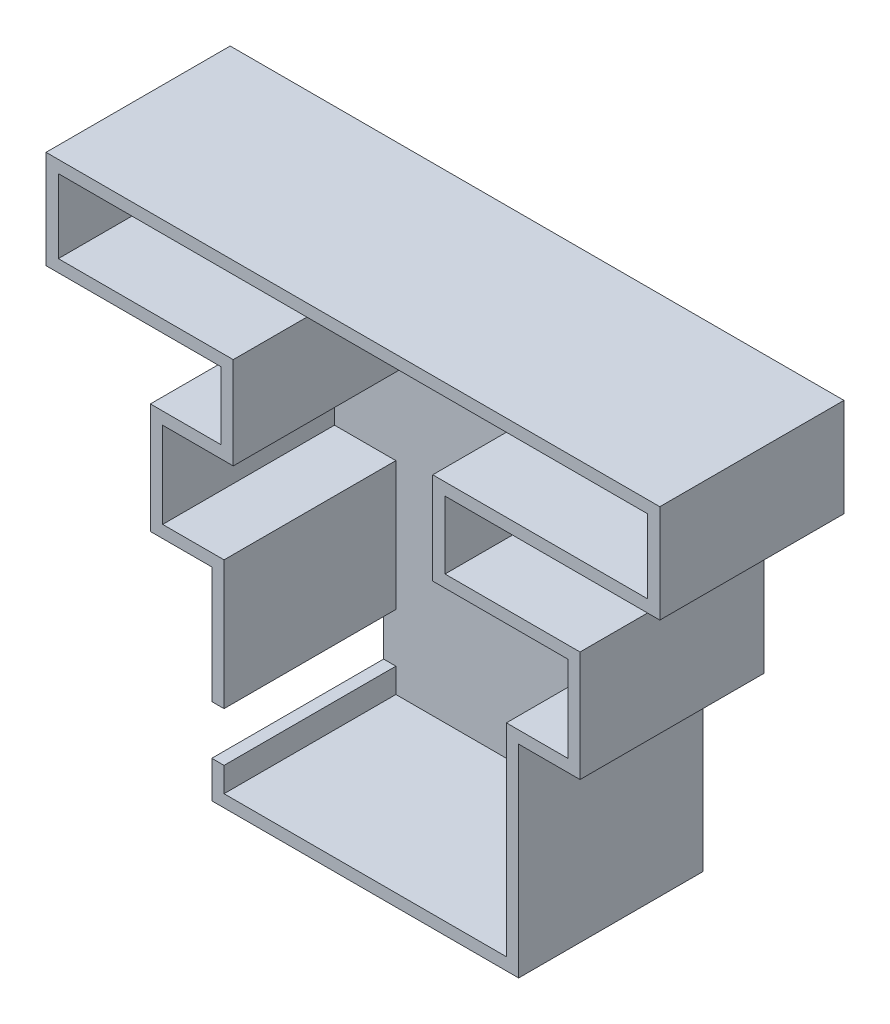
from build123d import *

# Parameters (mm, degrees)
EXTRUDE_1_DEPTH     = 15
CUT_EXTRUDE_1_DEPTH = 14
SKETCH_7_W          = 48
SKETCH_7_H          = 6
CUT_EXTRUDE_2_DEPTH = 1
SKETCH_8_W          = 14
SKETCH_8_H          = 4
CUT_EXTRUDE_3_DEPTH = 1


with BuildPart() as part:
    # 草图3 → 凸台-拉伸1 (new body)
    with BuildSketch(Plane.XY):
        Polygon((-26, 21.5), (24, 21.5), (24, 13.5), (6.5, 13.5), (6.5, 8), (17.5, 8), (17.5, -1), (12.5, -1), (12.5, -17.5), (-12.5, -17.5), (-12.5, -1), (-17.5, -1), (-17.5, 8), (-11.75, 8), (-11.75, 13.5), (-26, 13.5), align=None)
    extrude(amount=EXTRUDE_1_DEPTH)

    # 草图4 → 切除-拉伸1 (cut)
    with BuildSketch(Plane.XY.offset(15)):
        Polygon((23, 20.5), (-25, 20.5), (-25, 14.5), (-10.75, 14.5), (-10.75, 7), (-16.5, 7), (-16.5, 0), (-11.5, 0), (-11.5, -16.5), (11.5, -16.5), (11.5, 0), (16.5, 0), (16.5, 7), (5.5, 7), (5.5, 14.5), (23, 14.5), align=None)
    extrude(amount=-CUT_EXTRUDE_1_DEPTH, mode=Mode.SUBTRACT)

    # 草图7 → 切除-拉伸2 (cut)
    with BuildSketch(Plane.XY.offset(1)):
        with Locations((-1, 17.5)):
            Rectangle(SKETCH_7_W, SKETCH_7_H)
    extrude(amount=-CUT_EXTRUDE_2_DEPTH, mode=Mode.SUBTRACT)

    # 草图8 → 切除-拉伸3 (cut)
    with BuildSketch(Plane.ZY.offset(12.5)):
        with Locations((8, -12.5)):
            Rectangle(SKETCH_8_W, SKETCH_8_H)
    extrude(amount=-CUT_EXTRUDE_3_DEPTH, mode=Mode.SUBTRACT)


solid = part.part
